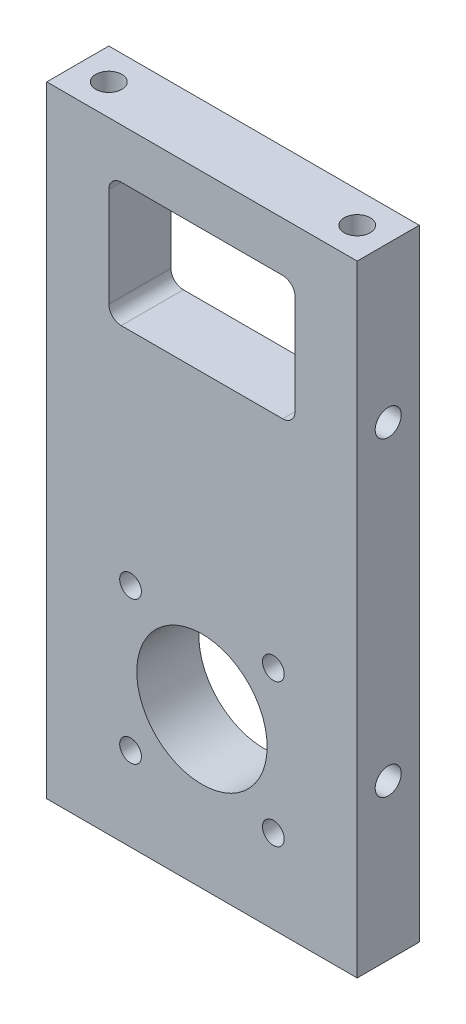
from build123d import *

# Parameters (mm, degrees)
SKETCH1_W                 = 50
SKETCH1_H                 = 10
BOSS_EXTRUDE1_DEPTH       = 100
M5X0_8_TAPPED_HOLE1_D     = 4.2
M5X0_8_TAPPED_HOLE1_DEPTH = 14
M5X0_8_TAPPED_HOLE1_TIP   = 1.2618073
M5X0_8_TAPPED_HOLE2_D     = 4.2
M5X0_8_TAPPED_HOLE2_DEPTH = 14
M5X0_8_TAPPED_HOLE2_TIP   = 1.2618073
M5X0_8_TAPPED_HOLE3_D     = 4.2
M5X0_8_TAPPED_HOLE3_DEPTH = 8
M5X0_8_TAPPED_HOLE3_TIP   = 1.2618073
M5X0_8_TAPPED_HOLE4_D     = 4.2
M5X0_8_TAPPED_HOLE4_DEPTH = 8
M5X0_8_TAPPED_HOLE4_TIP   = 1.2618073
CUT_EXTRUDE2_REACH        = 12
SKETCH11_R                = 10.5
SKETCH11_R_2              = 1.75
SKETCH11_W                = 30
SKETCH11_H                = 20
FILLET2_R                 = 2


with BuildPart() as part:
    # Sketch1 → Boss-Extrude1 (new body)
    with BuildSketch(Plane(origin=(0, 0, 0), x_dir=(1, 0, 0), z_dir=(0, 1, 0))):
        with Locations((-1.051745534, -389.692172039)):
            Rectangle(SKETCH1_W, SKETCH1_H)
    extrude(amount=BOSS_EXTRUDE1_DEPTH)

    # M5x0.8 Tapped Hole1
    with Locations(Plane.XZ):
        with Locations((18.948254466, 389.692172039), (-21.051745534, 389.692172039)):
            Hole(M5X0_8_TAPPED_HOLE1_D / 2, depth=M5X0_8_TAPPED_HOLE1_DEPTH)
            with Locations((0, 0, -(M5X0_8_TAPPED_HOLE1_DEPTH + M5X0_8_TAPPED_HOLE1_TIP / 2))):  # 118° drill point
                Cone(0, M5X0_8_TAPPED_HOLE1_D / 2, M5X0_8_TAPPED_HOLE1_TIP, mode=Mode.SUBTRACT)

    # M5x0.8 Tapped Hole2
    with Locations(Plane(origin=(0, 100, 0), x_dir=(-1, 0, 0), z_dir=(0, 1, 0))):
        with Locations((21.051745534, 389.692172039), (-18.948254466, 389.692172039)):
            Hole(M5X0_8_TAPPED_HOLE2_D / 2, depth=M5X0_8_TAPPED_HOLE2_DEPTH)
            with Locations((0, 0, -(M5X0_8_TAPPED_HOLE2_DEPTH + M5X0_8_TAPPED_HOLE2_TIP / 2))):  # 118° drill point
                Cone(0, M5X0_8_TAPPED_HOLE2_D / 2, M5X0_8_TAPPED_HOLE2_TIP, mode=Mode.SUBTRACT)

    # M5x0.8 Tapped Hole3
    with Locations(Plane.ZY.offset(26.051745534)):
        with Locations((389.692172039, 75), (389.692172039, 25)):
            Hole(M5X0_8_TAPPED_HOLE3_D / 2, depth=M5X0_8_TAPPED_HOLE3_DEPTH)
            with Locations((0, 0, -(M5X0_8_TAPPED_HOLE3_DEPTH + M5X0_8_TAPPED_HOLE3_TIP / 2))):  # 118° drill point
                Cone(0, M5X0_8_TAPPED_HOLE3_D / 2, M5X0_8_TAPPED_HOLE3_TIP, mode=Mode.SUBTRACT)

    # M5x0.8 Tapped Hole4
    with Locations(Plane(origin=(23.948254466, 0, 0), x_dir=(0, 0, -1), z_dir=(1, 0, 0))):
        with Locations((-389.692172039, 75), (-389.692172039, 25)):
            Hole(M5X0_8_TAPPED_HOLE4_D / 2, depth=M5X0_8_TAPPED_HOLE4_DEPTH)
            with Locations((0, 0, -(M5X0_8_TAPPED_HOLE4_DEPTH + M5X0_8_TAPPED_HOLE4_TIP / 2))):  # 118° drill point
                Cone(0, M5X0_8_TAPPED_HOLE4_D / 2, M5X0_8_TAPPED_HOLE4_TIP, mode=Mode.SUBTRACT)

    # Sketch11 → Cut-Extrude2 (cut, up to next)
    with BuildSketch(Plane.XY.offset(394.692172039), mode=Mode.PRIVATE) as cut_extrude2_sk1:
        with Locations((-1.051745534, 25)):
            Circle(SKETCH11_R)
    cut_extrude2_tool1 = extrude(cut_extrude2_sk1.sketch, amount=-CUT_EXTRUDE2_REACH, mode=Mode.PRIVATE) & part.part
    add(cut_extrude2_tool1.solids().sort_by_distance((-1.051746, 25, 394.692172))[0], mode=Mode.SUBTRACT)
    # Sketch11 → Cut-Extrude2 (cut, up to next)
    with BuildSketch(Plane.XY.offset(394.692172039), mode=Mode.PRIVATE) as cut_extrude2_sk2:
        with Locations((-12.551745534, 36.5)):
            Circle(SKETCH11_R_2)
    cut_extrude2_tool2 = extrude(cut_extrude2_sk2.sketch, amount=-CUT_EXTRUDE2_REACH, mode=Mode.PRIVATE) & part.part
    add(cut_extrude2_tool2.solids().sort_by_distance((-12.551746, 36.5, 394.692172))[0], mode=Mode.SUBTRACT)
    # Sketch11 → Cut-Extrude2 (cut, up to next)
    with BuildSketch(Plane.XY.offset(394.692172039), mode=Mode.PRIVATE) as cut_extrude2_sk3:
        with Locations((10.448254466, 36.5)):
            Circle(SKETCH11_R_2)
    cut_extrude2_tool3 = extrude(cut_extrude2_sk3.sketch, amount=-CUT_EXTRUDE2_REACH, mode=Mode.PRIVATE) & part.part
    add(cut_extrude2_tool3.solids().sort_by_distance((10.448254, 36.5, 394.692172))[0], mode=Mode.SUBTRACT)
    # Sketch11 → Cut-Extrude2 (cut, up to next)
    with BuildSketch(Plane.XY.offset(394.692172039), mode=Mode.PRIVATE) as cut_extrude2_sk4:
        with Locations((10.448254466, 13.5)):
            Circle(SKETCH11_R_2)
    cut_extrude2_tool4 = extrude(cut_extrude2_sk4.sketch, amount=-CUT_EXTRUDE2_REACH, mode=Mode.PRIVATE) & part.part
    add(cut_extrude2_tool4.solids().sort_by_distance((10.448254, 13.5, 394.692172))[0], mode=Mode.SUBTRACT)
    # Sketch11 → Cut-Extrude2 (cut, up to next)
    with BuildSketch(Plane.XY.offset(394.692172039), mode=Mode.PRIVATE) as cut_extrude2_sk5:
        with Locations((-12.551745534, 13.5)):
            Circle(SKETCH11_R_2)
    cut_extrude2_tool5 = extrude(cut_extrude2_sk5.sketch, amount=-CUT_EXTRUDE2_REACH, mode=Mode.PRIVATE) & part.part
    add(cut_extrude2_tool5.solids().sort_by_distance((-12.551746, 13.5, 394.692172))[0], mode=Mode.SUBTRACT)
    # Sketch11 → Cut-Extrude2 (cut, up to next)
    with BuildSketch(Plane.XY.offset(394.692172039), mode=Mode.PRIVATE) as cut_extrude2_sk6:
        with Locations((-1.051745534, 82)):
            Rectangle(SKETCH11_W, SKETCH11_H)
    cut_extrude2_tool6 = extrude(cut_extrude2_sk6.sketch, amount=-CUT_EXTRUDE2_REACH, mode=Mode.PRIVATE) & part.part
    add(cut_extrude2_tool6.solids().sort_by_distance((-1.051746, 82, 394.692172))[0], mode=Mode.SUBTRACT)

    # Fillet2
    fillet2_edges = [part.edges().sort_by_distance(p)[0] for p in [
        (-16.051745534, 72, 389.692172039),
        (-16.051745534, 92, 389.692172039),
        (13.948254466, 92, 389.692172039),
        (13.948254466, 72, 389.692172039),
    ]]
    fillet(fillet2_edges, radius=FILLET2_R)


solid = part.part
